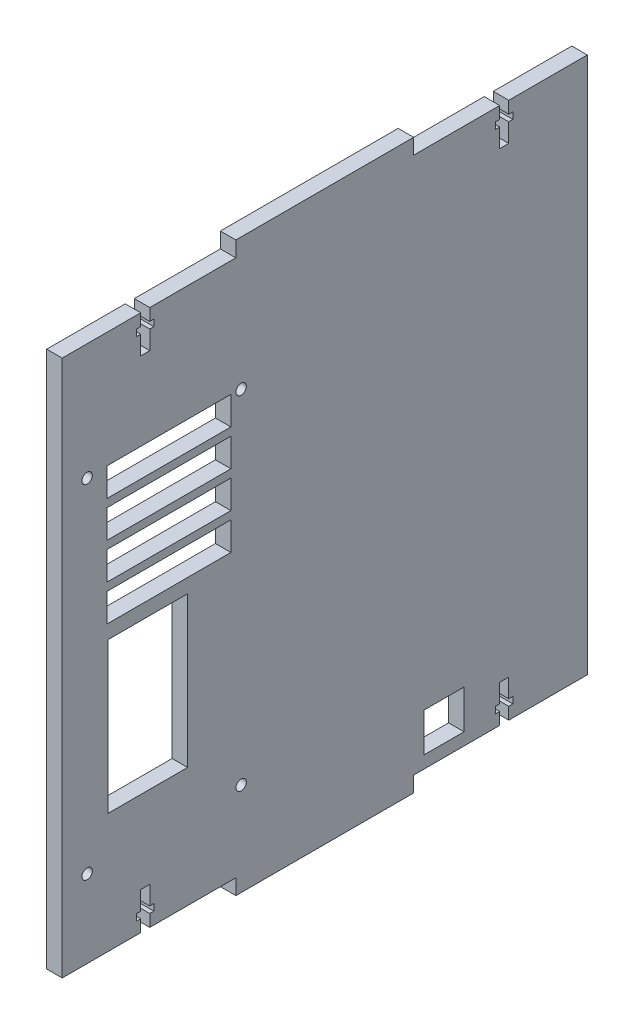
from build123d import *

# Parameters (mm, degrees)
SKETCH1_W                  = 173.89
SKETCH1_H                  = 177.8
BOSS_EXTRUDE1_DEPTH        = 5.13
SKETCH6_W                  = 5.13
SKETCH6_H                  = 58.88
TEETH_DEPTH                = 5.13
T_SLOT_DEPTH               = 5.13
T_SLOT_PATTERN_COUNT       = 2
T_SLOT_PATTERN_PITCH       = 118.88
T_SLOT_BOTTOM_COPY_1_DEPTH = 5.13
SKETCH3_W                  = 26.322180797
SKETCH3_H                  = 49.826019937
POWER_PORT_DEPTH           = 5.13
POWER_SUPPLY_SCREWS_REACH  = 198.675
SKETCH7_R                  = 1.7145
SKETCH4_W                  = 41
SKETCH4_H                  = 9.354563129
FAN_VENT_DEPTH             = 5.13
LPATTERN3_COUNT            = 4
LPATTERN3_PITCH            = 12
SKETCH5_W                  = 13.315736025
SKETCH5_H                  = 12.842697729
USB_PORT_DEPTH             = 5.13
SKETCH11_W                 = 5.13
SKETCH11_H                 = 58.88
BOSS_EXTRUDE2_DEPTH        = 5.13
LPATTERN4_COUNT            = 2
LPATTERN4_PITCH            = 51
LPATTERN4_COUNT_DIR2       = 2
LPATTERN4_PITCH_DIR2       = 113.5


with BuildPart() as part:
    # Sketch1 → Boss-Extrude1 (new body)
    with BuildSketch(Plane(origin=(0, 0, 0), x_dir=(0, 0, -1), z_dir=(1, 0, 0))):
        with Locations((51.252197546, -50.943101868)):
            Rectangle(SKETCH1_W, SKETCH1_H)
    extrude(amount=BOSS_EXTRUDE1_DEPTH)

    # Sketch6 → teeth (add)
    with BuildSketch(Plane(origin=(0, 37.956898132, 0), x_dir=(1, 0, 0), z_dir=(0, 1, 0))):
        with Locations((2.565, 51.252197546)):
            Rectangle(SKETCH6_W, SKETCH6_H)
    extrude(amount=TEETH_DEPTH)

    # Sketch2 → t-slot (cut)
    with BuildSketch(Plane(origin=(5.13, 0, 0), x_dir=(0, 0, -1), z_dir=(1, 0, 0))):
        Polygon((-9.687802454, 37.956898132), (-6.690802454, 37.956898132), (-6.690802454, 33.961898132), (-5.331802454, 33.961898132), (-5.331802454, 31.794898132), (-6.690802454, 31.794898132), (-6.690802454, 25.587898132), (-9.687802454, 25.587898132), (-9.687802454, 31.794898132), (-11.046802454, 31.794898132), (-11.046802454, 33.961898132), (-9.687802454, 33.961898132), align=None)
    t_slot = extrude(amount=-T_SLOT_DEPTH, mode=Mode.SUBTRACT)

    # t-slot pattern: t-slot ×2
    with Locations(*[(0, 0, -i * T_SLOT_PATTERN_PITCH) for i in range(1, T_SLOT_PATTERN_COUNT)]):
        add(t_slot, mode=Mode.SUBTRACT)

    # t-slot bottom: t-slot across plane
    add(t_slot.mirror(Plane(origin=(0, -50.943101868, 0), x_dir=(0, 0, 1), z_dir=(0, -1, 0))), mode=Mode.SUBTRACT)

    # t-slot bottom copy 1 sketch → t-slot bottom copy 1 (cut)
    with BuildSketch(Plane(origin=(5.13, -101.886203737, -118.88), x_dir=(0, 0, -1), z_dir=(1, 0, 0))):
        Polygon((-9.687802454, -37.956898132), (-6.690802454, -37.956898132), (-6.690802454, -33.961898132), (-5.331802454, -33.961898132), (-5.331802454, -31.794898132), (-6.690802454, -31.794898132), (-6.690802454, -25.587898132), (-9.687802454, -25.587898132), (-9.687802454, -31.794898132), (-11.046802454, -31.794898132), (-11.046802454, -33.961898132), (-9.687802454, -33.961898132), align=None)
    extrude(amount=-T_SLOT_BOTTOM_COPY_1_DEPTH, mode=Mode.SUBTRACT)

    # Sketch3 → power port (cut)
    with BuildSketch(Plane(origin=(5.13, 0, 0), x_dir=(0, 0, -1), z_dir=(1, 0, 0))):
        with Locations((-7.323344752, -75.302440375)):
            Rectangle(SKETCH3_W, SKETCH3_H)
    extrude(amount=-POWER_PORT_DEPTH, mode=Mode.SUBTRACT)

    # Sketch7 → Power supply screws (cut, up to next)
    with BuildSketch(Plane(origin=(5.13, 0, 0), x_dir=(0, 0, -1), z_dir=(1, 0, 0)), mode=Mode.PRIVATE) as power_supply_screws_sk1:
        with Locations((-27.442802454, -0.593101868)):
            Circle(SKETCH7_R)
    power_supply_screws_tool1 = extrude(power_supply_screws_sk1.sketch, amount=-POWER_SUPPLY_SCREWS_REACH, mode=Mode.PRIVATE) & part.part
    power_supply_screws = power_supply_screws_tool1.solids().sort_by_distance((5.13, -0.593102, 27.442802))[0]
    add(power_supply_screws, mode=Mode.SUBTRACT)

    # Sketch4 → fan vent (cut)
    with BuildSketch(Plane(origin=(5.13, 0, 0), x_dir=(0, 0, -1), z_dir=(1, 0, 0))):
        with Locations((-0.321795885, -5.04966493)):
            Rectangle(SKETCH4_W, SKETCH4_H)
    fan_vent = extrude(amount=-FAN_VENT_DEPTH, mode=Mode.SUBTRACT)

    # LPattern3: fan vent ×4
    with Locations(*[(0, -i * LPATTERN3_PITCH, 0) for i in range(1, LPATTERN3_COUNT)]):
        add(fan_vent, mode=Mode.SUBTRACT)

    # Sketch5 → USB port (cut)
    with BuildSketch(Plane(origin=(5.13, 0, 0), x_dir=(0, 0, -1), z_dir=(1, 0, 0))):
        with Locations((90.737265655, -129.344754623)):
            Rectangle(SKETCH5_W, SKETCH5_H)
    extrude(amount=-USB_PORT_DEPTH, mode=Mode.SUBTRACT)

    # Sketch11 → Boss-Extrude2 (add)
    with BuildSketch(Plane.XZ.offset(139.843101868)):
        with Locations((2.565, -51.252197546)):
            Rectangle(SKETCH11_W, SKETCH11_H)
    extrude(amount=BOSS_EXTRUDE2_DEPTH)

    # LPattern4: Power supply screws 2 × 2
    with Locations(*[(0, -j * LPATTERN4_PITCH_DIR2, -i * LPATTERN4_PITCH) for i in range(LPATTERN4_COUNT) for j in range(LPATTERN4_COUNT_DIR2) if (i, j) != (0, 0)]):
        add(power_supply_screws, mode=Mode.SUBTRACT)


solid = part.part
